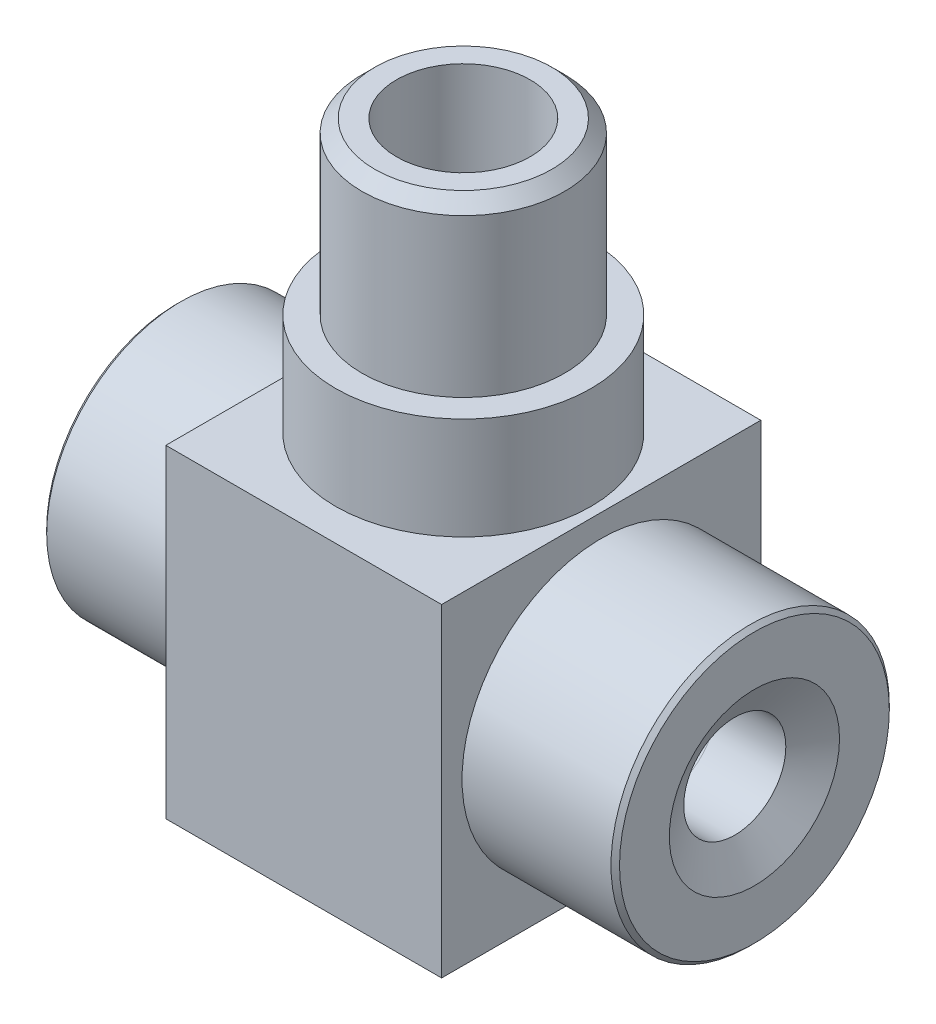
from build123d import *

# Parameters (mm, degrees)
SKETCH_1_W          = 32.4
SKETCH_1_H          = 38
EXTRUDE_1_DEPTH     = 37.5
SKETCH_4_R          = 15.75
EXTRUDE_2_DEPTH     = 17.5
SKETCH_5_R          = 9.3
CUT_EXTRUDE_1_DEPTH = 18
SKETCH_6_R          = 4
CUT_EXTRUDE_2_DEPTH = 2.4
SKETCH_7_R          = 2
CUT_EXTRUDE_3_DEPTH = 18.6
SKETCH_8_R          = 16.35
EXTRUDE_3_DEPTH     = 18
SKETCH_9_R          = 6
CUT_EXTRUDE_4_DEPTH = 12.5
CHAMFER_1_SIZE      = 4
CHAMFER_1_SIZE2     = 2.309401077
SKETCH_10_R         = 2.5
CUT_EXTRUDE_5_DEPTH = 21.7
FILLET_1_R          = 2
SKETCH_11_R         = 15
EXTRUDE_4_DEPTH     = 12
SKETCH_12_R         = 11.9
EXTRUDE_5_DEPTH     = 20
SKETCH_13_R         = 7.85
CUT_EXTRUDE_6_DEPTH = 17
SKETCH_14_R         = 4.5
CUT_EXTRUDE_7_DEPTH = 42
CHAMFER_2_SIZE      = 1.5
CHAMFER_4_SIZE      = 0.5
CHAMFER_5_SIZE      = 0.5
SKETCH_15_R         = 3.5
CUT_EXTRUDE_8_DEPTH = 6
CHAMFER_6_SIZE      = 5
CHAMFER_6_SIZE2     = 2.500539856


with BuildPart() as part:
    # Эскиз1 → Бобышка-Вытянуть1 (new body)
    with BuildSketch(Plane.XY):
        with Locations((16.2, 19)):
            Rectangle(SKETCH_1_W, SKETCH_1_H)
    extrude(amount=EXTRUDE_1_DEPTH)

    # Эскиз4 → Бобышка-Вытянуть2 (add)
    with BuildSketch(Plane.ZY):
        with Locations((18.75, 19)):
            Circle(SKETCH_4_R)
    extrude(amount=EXTRUDE_2_DEPTH)

    # Эскиз5 → Вырез-Вытянуть1 (cut)
    with BuildSketch(Plane.ZY.offset(17.5)):
        with Locations((18.75, 19)):
            Circle(SKETCH_5_R)
    extrude(amount=-CUT_EXTRUDE_1_DEPTH, mode=Mode.SUBTRACT)

    # Эскиз6 → Вырез-Вытянуть2 (cut)
    with BuildSketch(Plane.ZY.offset(-0.5)):
        with Locations((18.75, 19)):
            Circle(SKETCH_6_R)
    extrude(amount=-CUT_EXTRUDE_2_DEPTH, mode=Mode.SUBTRACT)

    # Эскиз7 → Вырез-Вытянуть3 (cut)
    with BuildSketch(Plane.ZY.offset(-0.5)):
        with Locations((18.75, 15)):
            Circle(SKETCH_7_R)
    extrude(amount=-CUT_EXTRUDE_3_DEPTH, mode=Mode.SUBTRACT)

    # Эскиз8 → Бобышка-Вытянуть3 (add)
    with BuildSketch(Plane(origin=(32.4, 0, 0), x_dir=(0, 0, -1), z_dir=(1, 0, 0))):
        with Locations((-18.75, 19)):
            Circle(SKETCH_8_R)
    extrude(amount=EXTRUDE_3_DEPTH)

    # Эскиз9 → Вырез-Вытянуть4 (cut)
    with BuildSketch(Plane(origin=(50.4, 0, 0), x_dir=(0, 0, -1), z_dir=(1, 0, 0))):
        with Locations((-18.75, 19)):
            Circle(SKETCH_9_R)
    extrude(amount=-CUT_EXTRUDE_4_DEPTH, mode=Mode.SUBTRACT)

    # Фаска1
    chamfer_1_edges = [part.edges().sort_by_distance(p)[0] for p in [
        (50.4, 19, 24.75),
    ]]
    chamfer_1_side = [part.faces().sort_by_distance(p)[0] for p in [
        (50.4, 19, 34.637552165),
    ]]
    chamfer(chamfer_1_edges, length=CHAMFER_1_SIZE, length2=CHAMFER_1_SIZE2, reference=chamfer_1_side[0])

    # Эскиз10 → Вырез-Вытянуть5 (cut)
    with BuildSketch(Plane(origin=(37.9, 0, 0), x_dir=(0, 0, -1), z_dir=(1, 0, 0))):
        with Locations((-18.75, 19)):
            Circle(SKETCH_10_R)
    extrude(amount=-CUT_EXTRUDE_5_DEPTH, mode=Mode.SUBTRACT)

    # Скругление1
    fillet_1_edges = [part.edges().sort_by_distance(p)[0] for p in [
        (37.9, 19, 24.75),
    ]]
    fillet(fillet_1_edges, radius=FILLET_1_R)

    # Эскиз11 → Бобышка-Вытянуть4 (add)
    with BuildSketch(Plane(origin=(0, 38, 0), x_dir=(1, 0, 0), z_dir=(0, 1, 0))):
        with Locations((16.2, -18.75)):
            Circle(SKETCH_11_R)
    extrude(amount=EXTRUDE_4_DEPTH)

    # Эскиз12 → Бобышка-Вытянуть5 (add)
    with BuildSketch(Plane(origin=(0, 50, 0), x_dir=(1, 0, 0), z_dir=(0, 1, 0))):
        with Locations((16.2, -18.75)):
            Circle(SKETCH_12_R)
    extrude(amount=EXTRUDE_5_DEPTH)

    # Эскиз13 → Вырез-Вытянуть6 (cut)
    with BuildSketch(Plane(origin=(0, 70, 0), x_dir=(1, 0, 0), z_dir=(0, 1, 0))):
        with Locations((16.2, -18.75)):
            Circle(SKETCH_13_R)
    extrude(amount=-CUT_EXTRUDE_6_DEPTH, mode=Mode.SUBTRACT)

    # Эскиз14 → Вырез-Вытянуть7 (cut)
    with BuildSketch(Plane(origin=(0, 53, 0), x_dir=(1, 0, 0), z_dir=(0, 1, 0))):
        with Locations((16.2, -18.75)):
            Circle(SKETCH_14_R)
    extrude(amount=-CUT_EXTRUDE_7_DEPTH, mode=Mode.SUBTRACT)

    # Фаска2
    chamfer_2_edges = [part.edges().sort_by_distance(p)[0] for p in [
        (4.3, 70, 18.75),
    ]]
    chamfer(chamfer_2_edges, length=CHAMFER_2_SIZE)

    # Фаска4
    chamfer_4_edges = [part.edges().sort_by_distance(p)[0] for p in [
        (-17.5, 19, 3),
    ]]
    chamfer(chamfer_4_edges, length=CHAMFER_4_SIZE)

    # Фаска5
    chamfer_5_edges = [part.edges().sort_by_distance(p)[0] for p in [
        (50.4, 19, 35.1),
    ]]
    chamfer(chamfer_5_edges, length=CHAMFER_5_SIZE)

    # Эскиз15 → Вырез-Вытянуть8 (cut)
    with BuildSketch(Plane(origin=(0, 11, 0), x_dir=(1, 0, 0), z_dir=(0, 1, 0))):
        with Locations((16.2, -18.75)):
            Circle(SKETCH_15_R)
    extrude(amount=-CUT_EXTRUDE_8_DEPTH, mode=Mode.SUBTRACT)

    # Фаска6
    chamfer_6_edges = [part.edges().sort_by_distance(p)[0] for p in [
        (12.7, 5, 18.75),
    ]]
    chamfer_6_side = [part.faces().sort_by_distance(p)[0] for p in [
        (12.7, 8, 18.75),
    ]]
    chamfer(chamfer_6_edges, length=CHAMFER_6_SIZE, length2=CHAMFER_6_SIZE2, reference=chamfer_6_side[0])


solid = part.part
